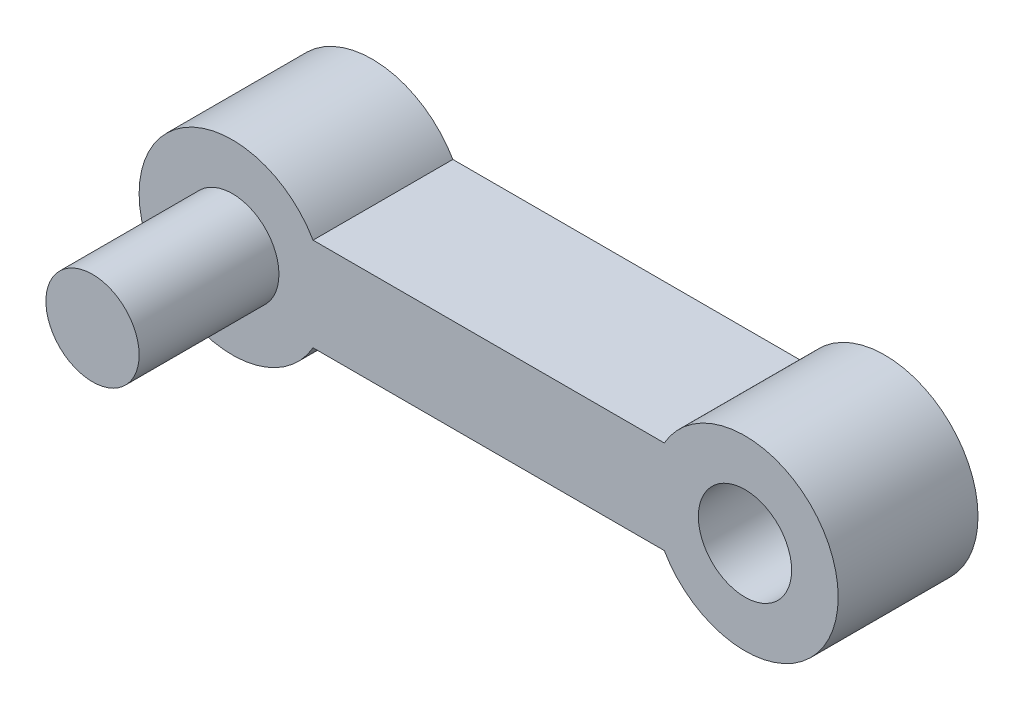
from build123d import *

# Parameters (mm, degrees)
BOSS_EXTRUDE1_DEPTH = 3
SKETCH3_R           = 1
BOSS_EXTRUDE2_DEPTH = 3
SKETCH4_R           = 1
CUT_EXTRUDE1_DEPTH  = 3


with BuildPart() as part:
    # Sketch2 → Boss-Extrude1 (new body)
    with BuildSketch(Plane.XY):
        with BuildLine():
            Line((-36.5050045, 13.800340042), (-28.969106115, 13.800340042))
            ThreePointArc((-28.969106115, 13.800340042), (-25.237055307, 12.800340042), (-28.969106115, 11.800340042))
            Line((-28.969106115, 11.800340042), (-36.5050045, 11.800340042))
            ThreePointArc((-36.5050045, 11.800340042), (-40.237055307, 12.800340042), (-36.5050045, 13.800340042))
        make_face()
    extrude(amount=BOSS_EXTRUDE1_DEPTH)

    # Sketch3 → Boss-Extrude2 (add)
    with BuildSketch(Plane.XY.offset(3)):
        with Locations((-38.237055307, 12.800340042)):
            Circle(SKETCH3_R)
    extrude(amount=BOSS_EXTRUDE2_DEPTH)

    # Sketch4 → Cut-Extrude1 (cut)
    with BuildSketch(Plane(origin=(0, 0, 0), x_dir=(-1, 0, 0), z_dir=(0, 0, -1))):
        with Locations((27.237055307, 12.800340042)):
            Circle(SKETCH4_R)
    extrude(amount=-CUT_EXTRUDE1_DEPTH, mode=Mode.SUBTRACT)


solid = part.part
